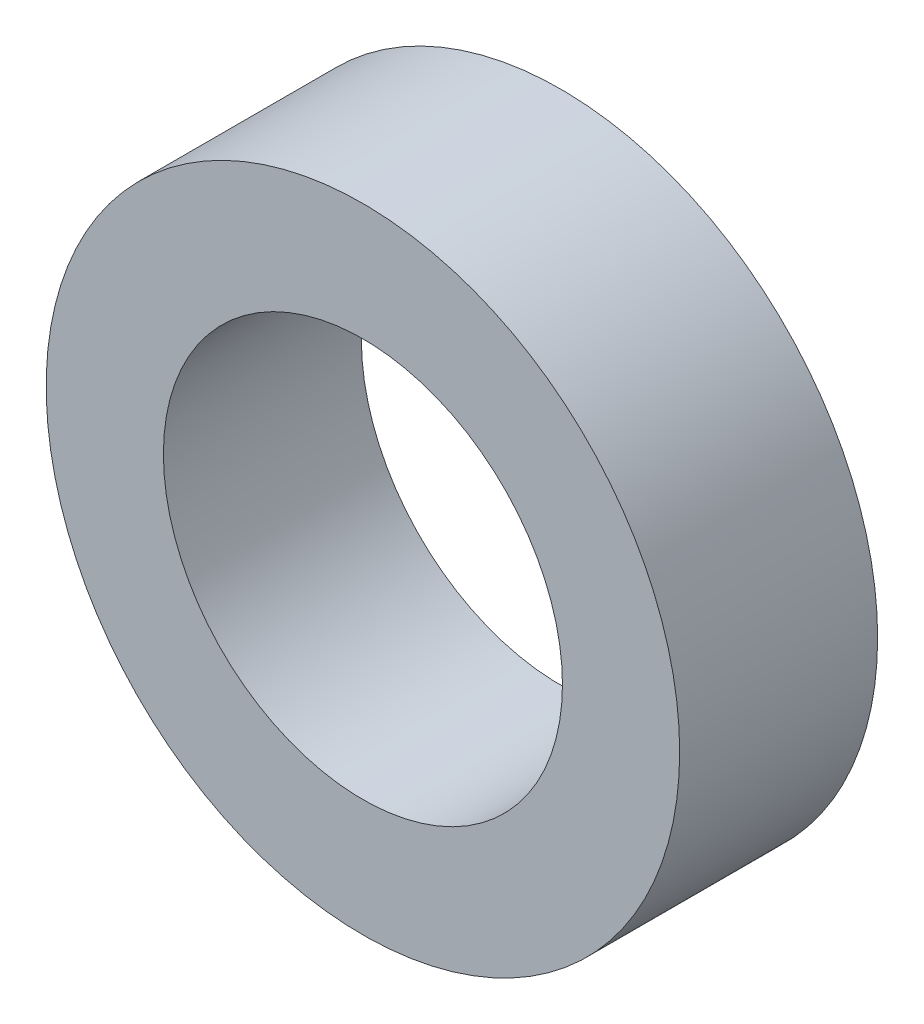
from build123d import *

# Parameters (mm, degrees)
SKETCH1_R           = 6.35
SKETCH1_R_2         = 4
BOSS_EXTRUDE1_DEPTH = 3.96875


with BuildPart() as part:
    # Sketch1 → Boss-Extrude1 (new body)
    with BuildSketch(Plane.XY):
        Circle(SKETCH1_R)
        Circle(SKETCH1_R_2, mode=Mode.SUBTRACT)
    extrude(amount=BOSS_EXTRUDE1_DEPTH)


solid = part.part
